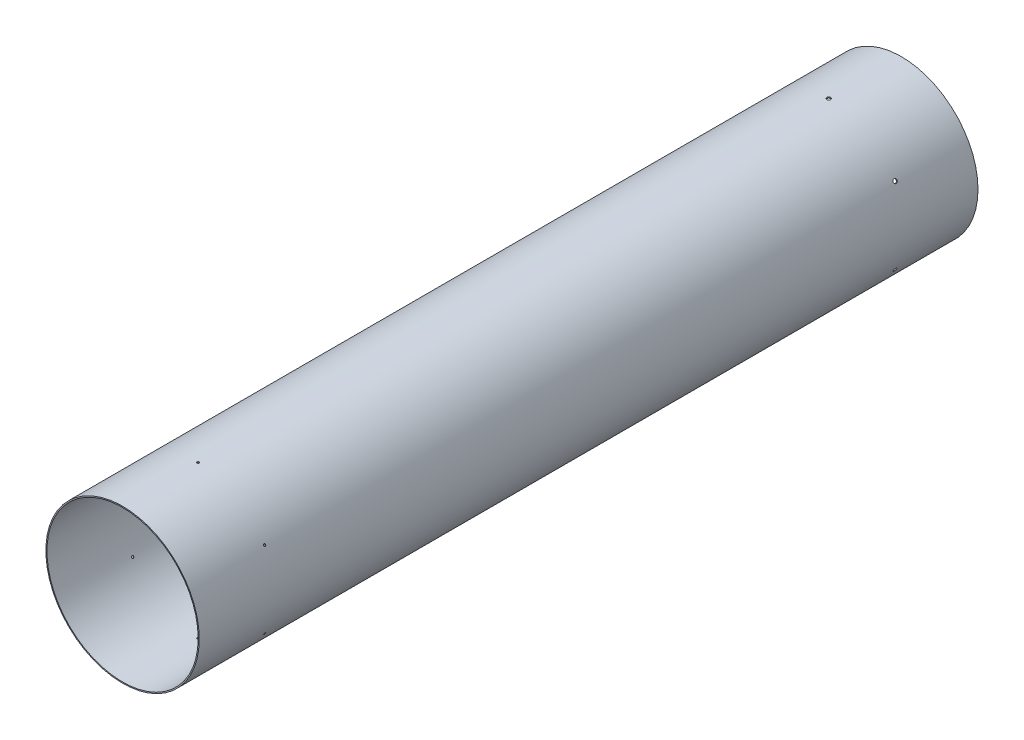
from build123d import *

# Parameters (mm, degrees)
SKETCH1_R                       = 80.518
SKETCH1_R_2                     = 79.375
BOSS_EXTRUDE1_DEPTH             = 817.5625
TAP_DRILL_FOR_10_32_TAP1_REACH  = 839.152
TAP_DRILL_FOR_10_32_TAP1_BORE_R = 2.0193
TAP_DRILL_FOR_4_40_TAP1_REACH   = 839.152
TAP_DRILL_FOR_4_40_TAP1_BORE_R  = 1.1303
CIRPATTERN1_COUNT               = 6


with BuildPart() as part:
    # Sketch1 → Boss-Extrude1 (new body)
    with BuildSketch(Plane.XY):
        Circle(SKETCH1_R)
        Circle(SKETCH1_R_2, mode=Mode.SUBTRACT)
    extrude(amount=BOSS_EXTRUDE1_DEPTH)

    # Tap Drill for #10-32 Tap1 bore → Tap Drill for #10-32 Tap1 (cut, up to next)
    with BuildSketch(Plane(origin=(0, 80.518, 0), x_dir=(1, 0, 0), z_dir=(0, 1, 0)), mode=Mode.PRIVATE) as tap_drill_for_10_32_tap1_sk1:
        with Locations((0, -76.2)):
            Circle(TAP_DRILL_FOR_10_32_TAP1_BORE_R)
    tap_drill_for_10_32_tap1_tool1 = extrude(tap_drill_for_10_32_tap1_sk1.sketch, amount=-TAP_DRILL_FOR_10_32_TAP1_REACH, mode=Mode.PRIVATE) & part.part
    tap_drill_for_10_32_tap1 = tap_drill_for_10_32_tap1_tool1.solids().sort_by_distance((0, 80.518, 76.2))[0]
    add(tap_drill_for_10_32_tap1, mode=Mode.SUBTRACT)

    # Tap Drill for #4-40 Tap1 bore → Tap Drill for #4-40 Tap1 (cut, up to next)
    with BuildSketch(Plane(origin=(0, 80.518, 0), x_dir=(1, 0, 0), z_dir=(0, 1, 0)), mode=Mode.PRIVATE) as tap_drill_for_4_40_tap1_sk1:
        with Locations((0, -738.1875)):
            Circle(TAP_DRILL_FOR_4_40_TAP1_BORE_R)
    tap_drill_for_4_40_tap1_tool1 = extrude(tap_drill_for_4_40_tap1_sk1.sketch, amount=-TAP_DRILL_FOR_4_40_TAP1_REACH, mode=Mode.PRIVATE) & part.part
    tap_drill_for_4_40_tap1 = tap_drill_for_4_40_tap1_tool1.solids().sort_by_distance((0, 80.518, 738.1875))[0]
    add(tap_drill_for_4_40_tap1, mode=Mode.SUBTRACT)

    # CirPattern1: Tap Drill for #10-32 Tap1, Tap Drill for #4-40 Tap1 ×6 about axis
    cirpattern1_axis = Axis((0, 0, 817.5625), (0, 0, 1))
    add([tap_drill_for_10_32_tap1.rotate(cirpattern1_axis, i * 360 / CIRPATTERN1_COUNT) for i in range(1, CIRPATTERN1_COUNT)], mode=Mode.SUBTRACT)
    add([tap_drill_for_4_40_tap1.rotate(cirpattern1_axis, i * 360 / CIRPATTERN1_COUNT) for i in range(1, CIRPATTERN1_COUNT)], mode=Mode.SUBTRACT)


solid = part.part
